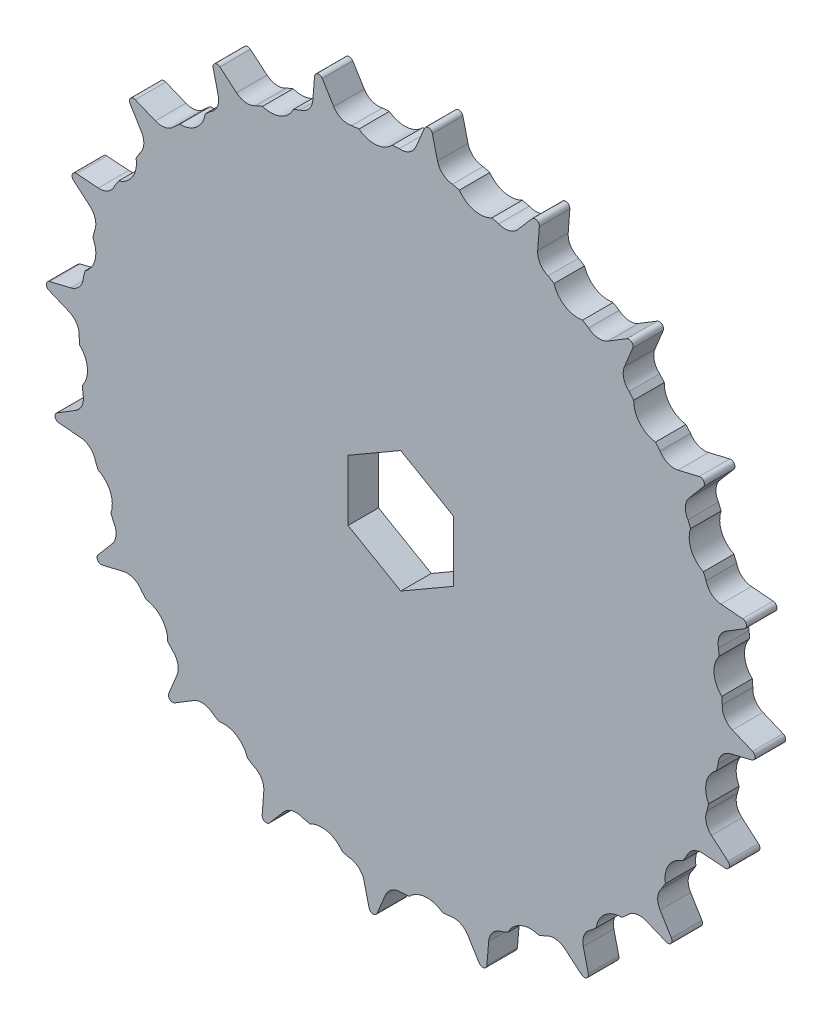
from build123d import *

# Parameters (mm, degrees)
BOSS_EXTRUDE1_DEPTH                 = 7.3
SKETCH2_R                           = 12.5
BOSS_EXTRUDE2_DEPTH                 = 40
FILLET1_R                           = 30
SKETCH3_R                           = 5
CUT_EXTRUDE1_DEPTH                  = 48.3
F_1_0MM_DOWEL_HOLE1_D               = 2.8
F_1_0MM_DOWEL_HOLE1_DEPTH           = 33.158795133
F_1_0MM_DOWEL_HOLE1_TIP             = 0.841204867
F_1_0MM_DOWEL_HOLE1_ON_FACE_2_D     = 2.8
F_1_0MM_DOWEL_HOLE1_ON_FACE_2_DEPTH = 33.158795133
F_1_0MM_DOWEL_HOLE1_ON_FACE_2_TIP   = 0.841204867
CUT_EXTRUDE2_DEPTH                  = 10
CIRPATTERN1_COUNT                   = 20
SKETCH6_W                           = 170.007054253
SKETCH6_H                           = 44.757292759
CUT_EXTRUDE3_DEPTH                  = 85.741056034
CUT_EXTRUDE3_DEPTH_BACK             = 85.741056034
CUT_EXTRUDE4_DEPTH                  = 1
CUT_EXTRUDE4_DEPTH_BACK             = 8.3


with BuildPart() as part:
    # Sketch1 → Boss-Extrude1 (new body)
    with BuildSketch(Plane.XY):
        with BuildLine():
            ThreePointArc((3.662609618, 79.321514688), (0, 76.88125), (-3.662609618, 79.321514688))
            Line((-3.662609618, 79.321514688), (-5.667701775, 84.126186191))
            ThreePointArc((-5.667701775, 84.126186191), (-6.669023137, 84.737973367), (-7.562311971, 83.977077135))
            Line((-7.562311971, 83.977077135), (-8.791101901, 78.917893592))
            ThreePointArc((-8.791101901, 78.917893592), (-12.026877215, 75.934714235), (-16.026135532, 77.77197684))
            Line((-16.026135532, 77.77197684), (-18.758157894, 82.203829344))
            ThreePointArc((-18.758157894, 82.203829344), (-19.842855928, 82.651443234), (-20.606116499, 81.760173735))
            Line((-20.606116499, 81.760173735), (-21.028347314, 76.571052042))
            ThreePointArc((-21.028347314, 76.571052042), (-23.757612799, 73.118413793), (-27.995044802, 74.307434811))
            Line((-27.995044802, 74.307434811), (-31.386725911, 78.2573414))
            ThreePointArc((-31.386725911, 78.2573414), (-32.528091751, 78.529760263), (-33.142530051, 77.530063512))
            Line((-33.142530051, 77.530063512), (-32.747805028, 72.338777067))
            ThreePointArc((-32.747805028, 72.338777067), (-34.903357108, 68.501695338), (-39.274623159, 69.013197125))
            Line((-39.274623159, 69.013197125), (-43.242448569, 72.38389799))
            ThreePointArc((-43.242448569, 72.38389799), (-44.412378001, 72.47441397), (-44.862864519, 71.390905818))
            Line((-44.862864519, 71.390905818), (-43.660903098, 66.325281321))
            ThreePointArc((-43.660903098, 66.325281321), (-45.189664928, 62.198237799), (-49.587129948, 62.019625484))
            Line((-49.587129948, 62.019625484), (-54.03339863, 64.728122783))
            ThreePointArc((-54.03339863, 64.728122783), (-55.203084108, 64.634507076), (-55.478526372, 63.49386709))
            Line((-55.478526372, 63.49386709), (-53.498924832, 58.678637028))
            ThreePointArc((-53.498924832, 58.678637028), (-54.363253221, 54.363253221), (-58.678637028, 53.498924832))
            Line((-58.678637028, 53.498924832), (-63.49386709, 55.478526372))
            ThreePointArc((-63.49386709, 55.478526372), (-64.634507076, 55.203084108), (-64.728122783, 54.03339863))
            Line((-64.728122783, 54.03339863), (-62.019625484, 49.587129948))
            ThreePointArc((-62.019625484, 49.587129948), (-62.198237799, 45.189664928), (-66.325281321, 43.660903098))
            Line((-66.325281321, 43.660903098), (-71.390905818, 44.862864519))
            ThreePointArc((-71.390905818, 44.862864519), (-72.47441397, 44.412378001), (-72.38389799, 43.242448569))
            Line((-72.38389799, 43.242448569), (-69.013197125, 39.274623159))
            ThreePointArc((-69.013197125, 39.274623159), (-68.501695338, 34.903357108), (-72.338777067, 32.747805028))
            Line((-72.338777067, 32.747805028), (-77.530063512, 33.142530051))
            ThreePointArc((-77.530063512, 33.142530051), (-78.529760263, 32.528091751), (-78.2573414, 31.386725911))
            Line((-78.2573414, 31.386725911), (-74.307434811, 27.995044802))
            ThreePointArc((-74.307434811, 27.995044802), (-73.118413793, 23.757612799), (-76.571052042, 21.028347314))
            Line((-76.571052042, 21.028347314), (-81.760173735, 20.606116499))
            ThreePointArc((-81.760173735, 20.606116499), (-82.651443234, 19.842855928), (-82.203829344, 18.758157894))
            Line((-82.203829344, 18.758157894), (-77.77197684, 16.026135532))
            ThreePointArc((-77.77197684, 16.026135532), (-75.934714235, 12.026877215), (-78.917893592, 8.791101901))
            Line((-78.917893592, 8.791101901), (-83.977077135, 7.562311971))
            ThreePointArc((-83.977077135, 7.562311971), (-84.737973367, 6.669023137), (-84.126186191, 5.667701775))
            Line((-84.126186191, 5.667701775), (-79.321514688, 3.662609618))
            ThreePointArc((-79.321514688, 3.662609618), (-76.88125, 0), (-79.321514688, -3.662609618))
            Line((-79.321514688, -3.662609618), (-84.126186191, -5.667701775))
            ThreePointArc((-84.126186191, -5.667701775), (-84.737973367, -6.669023137), (-83.977077135, -7.562311971))
            Line((-83.977077135, -7.562311971), (-78.917893592, -8.791101901))
            ThreePointArc((-78.917893592, -8.791101901), (-75.934714235, -12.026877215), (-77.77197684, -16.026135532))
            Line((-77.77197684, -16.026135532), (-82.203829344, -18.758157894))
            ThreePointArc((-82.203829344, -18.758157894), (-82.651443234, -19.842855928), (-81.760173735, -20.606116499))
            Line((-81.760173735, -20.606116499), (-76.571052042, -21.028347314))
            ThreePointArc((-76.571052042, -21.028347314), (-73.118413793, -23.757612799), (-74.307434811, -27.995044802))
            Line((-74.307434811, -27.995044802), (-78.2573414, -31.386725911))
            ThreePointArc((-78.2573414, -31.386725911), (-78.529760263, -32.528091751), (-77.530063512, -33.142530051))
            Line((-77.530063512, -33.142530051), (-72.338777067, -32.747805028))
            ThreePointArc((-72.338777067, -32.747805028), (-68.501695338, -34.903357108), (-69.013197125, -39.274623159))
            Line((-69.013197125, -39.274623159), (-72.38389799, -43.242448569))
            ThreePointArc((-72.38389799, -43.242448569), (-72.47441397, -44.412378001), (-71.390905818, -44.862864519))
            Line((-71.390905818, -44.862864519), (-66.325281321, -43.660903098))
            ThreePointArc((-66.325281321, -43.660903098), (-62.198237799, -45.189664928), (-62.019625484, -49.587129948))
            Line((-62.019625484, -49.587129948), (-64.728122783, -54.03339863))
            ThreePointArc((-64.728122783, -54.03339863), (-64.634507076, -55.203084108), (-63.49386709, -55.478526372))
            Line((-63.49386709, -55.478526372), (-58.678637028, -53.498924832))
            ThreePointArc((-58.678637028, -53.498924832), (-54.363253221, -54.363253221), (-53.498924832, -58.678637028))
            Line((-53.498924832, -58.678637028), (-55.478526372, -63.49386709))
            ThreePointArc((-55.478526372, -63.49386709), (-55.203084108, -64.634507076), (-54.03339863, -64.728122783))
            Line((-54.03339863, -64.728122783), (-49.587129948, -62.019625484))
            ThreePointArc((-49.587129948, -62.019625484), (-45.189664928, -62.198237799), (-43.660903098, -66.325281321))
            Line((-43.660903098, -66.325281321), (-44.862864519, -71.390905818))
            ThreePointArc((-44.862864519, -71.390905818), (-44.412378001, -72.47441397), (-43.242448569, -72.38389799))
            Line((-43.242448569, -72.38389799), (-39.274623159, -69.013197125))
            ThreePointArc((-39.274623159, -69.013197125), (-34.903357108, -68.501695338), (-32.747805028, -72.338777067))
            Line((-32.747805028, -72.338777067), (-33.142530051, -77.530063512))
            ThreePointArc((-33.142530051, -77.530063512), (-32.528091751, -78.529760263), (-31.386725911, -78.2573414))
            Line((-31.386725911, -78.2573414), (-27.995044802, -74.307434811))
            ThreePointArc((-27.995044802, -74.307434811), (-23.757612799, -73.118413793), (-21.028347314, -76.571052042))
            Line((-21.028347314, -76.571052042), (-20.606116499, -81.760173735))
            ThreePointArc((-20.606116499, -81.760173735), (-19.842855928, -82.651443234), (-18.758157894, -82.203829344))
            Line((-18.758157894, -82.203829344), (-16.026135532, -77.77197684))
            ThreePointArc((-16.026135532, -77.77197684), (-12.026877215, -75.934714235), (-8.791101901, -78.917893592))
            Line((-8.791101901, -78.917893592), (-7.562311971, -83.977077135))
            ThreePointArc((-7.562311971, -83.977077135), (-6.669023137, -84.737973367), (-5.667701775, -84.126186191))
            Line((-5.667701775, -84.126186191), (-3.662609618, -79.321514688))
            ThreePointArc((-3.662609618, -79.321514688), (0, -76.88125), (3.662609618, -79.321514688))
            Line((3.662609618, -79.321514688), (5.667701775, -84.126186191))
            ThreePointArc((5.667701775, -84.126186191), (6.669023137, -84.737973367), (7.562311971, -83.977077135))
            Line((7.562311971, -83.977077135), (8.791101901, -78.917893592))
            ThreePointArc((8.791101901, -78.917893592), (12.026877215, -75.934714235), (16.026135532, -77.77197684))
            Line((16.026135532, -77.77197684), (18.758157894, -82.203829344))
            ThreePointArc((18.758157894, -82.203829344), (19.842855928, -82.651443234), (20.606116499, -81.760173735))
            Line((20.606116499, -81.760173735), (21.028347314, -76.571052042))
            ThreePointArc((21.028347314, -76.571052042), (23.757612799, -73.118413793), (27.995044802, -74.307434811))
            Line((27.995044802, -74.307434811), (31.386725911, -78.2573414))
            ThreePointArc((31.386725911, -78.2573414), (32.528091751, -78.529760263), (33.142530051, -77.530063512))
            Line((33.142530051, -77.530063512), (32.747805028, -72.338777067))
            ThreePointArc((32.747805028, -72.338777067), (34.903357108, -68.501695338), (39.274623159, -69.013197125))
            Line((39.274623159, -69.013197125), (43.242448569, -72.38389799))
            ThreePointArc((43.242448569, -72.38389799), (44.412378001, -72.47441397), (44.862864519, -71.390905818))
            Line((44.862864519, -71.390905818), (43.660903098, -66.325281321))
            ThreePointArc((43.660903098, -66.325281321), (45.189664928, -62.198237799), (49.587129948, -62.019625484))
            Line((49.587129948, -62.019625484), (54.03339863, -64.728122783))
            ThreePointArc((54.03339863, -64.728122783), (55.203084108, -64.634507076), (55.478526372, -63.49386709))
            Line((55.478526372, -63.49386709), (53.498924832, -58.678637028))
            ThreePointArc((53.498924832, -58.678637028), (54.363253221, -54.363253221), (58.678637028, -53.498924832))
            Line((58.678637028, -53.498924832), (63.49386709, -55.478526372))
            ThreePointArc((63.49386709, -55.478526372), (64.634507076, -55.203084108), (64.728122783, -54.03339863))
            Line((64.728122783, -54.03339863), (62.019625484, -49.587129948))
            ThreePointArc((62.019625484, -49.587129948), (62.198237799, -45.189664928), (66.325281321, -43.660903098))
            Line((66.325281321, -43.660903098), (71.390905818, -44.862864519))
            ThreePointArc((71.390905818, -44.862864519), (72.47441397, -44.412378001), (72.38389799, -43.242448569))
            Line((72.38389799, -43.242448569), (69.013197125, -39.274623159))
            ThreePointArc((69.013197125, -39.274623159), (68.501695338, -34.903357108), (72.338777067, -32.747805028))
            Line((72.338777067, -32.747805028), (77.530063512, -33.142530051))
            ThreePointArc((77.530063512, -33.142530051), (78.529760263, -32.528091751), (78.2573414, -31.386725911))
            Line((78.2573414, -31.386725911), (74.307434811, -27.995044802))
            ThreePointArc((74.307434811, -27.995044802), (73.118413793, -23.757612799), (76.571052042, -21.028347314))
            Line((76.571052042, -21.028347314), (81.760173735, -20.606116499))
            ThreePointArc((81.760173735, -20.606116499), (82.651443234, -19.842855928), (82.203829344, -18.758157894))
            Line((82.203829344, -18.758157894), (77.77197684, -16.026135532))
            ThreePointArc((77.77197684, -16.026135532), (75.934714235, -12.026877215), (78.917893592, -8.791101901))
            Line((78.917893592, -8.791101901), (83.977077135, -7.562311971))
            ThreePointArc((83.977077135, -7.562311971), (84.737973367, -6.669023137), (84.126186191, -5.667701775))
            Line((84.126186191, -5.667701775), (79.321514688, -3.662609618))
            ThreePointArc((79.321514688, -3.662609618), (76.88125, 0), (79.321514688, 3.662609618))
            Line((79.321514688, 3.662609618), (84.126186191, 5.667701775))
            ThreePointArc((84.126186191, 5.667701775), (84.737973367, 6.669023137), (83.977077135, 7.562311971))
            Line((83.977077135, 7.562311971), (78.917893592, 8.791101901))
            ThreePointArc((78.917893592, 8.791101901), (75.934714235, 12.026877215), (77.77197684, 16.026135532))
            Line((77.77197684, 16.026135532), (82.203829344, 18.758157894))
            ThreePointArc((82.203829344, 18.758157894), (82.651443234, 19.842855928), (81.760173735, 20.606116499))
            Line((81.760173735, 20.606116499), (76.571052042, 21.028347314))
            ThreePointArc((76.571052042, 21.028347314), (73.118413793, 23.757612799), (74.307434811, 27.995044802))
            Line((74.307434811, 27.995044802), (78.2573414, 31.386725911))
            ThreePointArc((78.2573414, 31.386725911), (78.529760263, 32.528091751), (77.530063512, 33.142530051))
            Line((77.530063512, 33.142530051), (72.338777067, 32.747805028))
            ThreePointArc((72.338777067, 32.747805028), (68.501695338, 34.903357108), (69.013197125, 39.274623159))
            Line((69.013197125, 39.274623159), (72.38389799, 43.242448569))
            ThreePointArc((72.38389799, 43.242448569), (72.47441397, 44.412378001), (71.390905818, 44.862864519))
            Line((71.390905818, 44.862864519), (66.325281321, 43.660903098))
            ThreePointArc((66.325281321, 43.660903098), (62.198237799, 45.189664928), (62.019625484, 49.587129948))
            Line((62.019625484, 49.587129948), (64.728122783, 54.03339863))
            ThreePointArc((64.728122783, 54.03339863), (64.634507076, 55.203084108), (63.49386709, 55.478526372))
            Line((63.49386709, 55.478526372), (58.678637028, 53.498924832))
            ThreePointArc((58.678637028, 53.498924832), (54.363253221, 54.363253221), (53.498924832, 58.678637028))
            Line((53.498924832, 58.678637028), (55.478526372, 63.49386709))
            ThreePointArc((55.478526372, 63.49386709), (55.203084108, 64.634507076), (54.03339863, 64.728122783))
            Line((54.03339863, 64.728122783), (49.587129948, 62.019625484))
            ThreePointArc((49.587129948, 62.019625484), (45.189664928, 62.198237799), (43.660903098, 66.325281321))
            Line((43.660903098, 66.325281321), (44.862864519, 71.390905818))
            ThreePointArc((44.862864519, 71.390905818), (44.412378001, 72.47441397), (43.242448569, 72.38389799))
            Line((43.242448569, 72.38389799), (39.274623159, 69.013197125))
            ThreePointArc((39.274623159, 69.013197125), (34.903357108, 68.501695338), (32.747805028, 72.338777067))
            Line((32.747805028, 72.338777067), (33.142530051, 77.530063512))
            ThreePointArc((33.142530051, 77.530063512), (32.528091751, 78.529760263), (31.386725911, 78.2573414))
            Line((31.386725911, 78.2573414), (27.995044802, 74.307434811))
            ThreePointArc((27.995044802, 74.307434811), (23.757612799, 73.118413793), (21.028347314, 76.571052042))
            Line((21.028347314, 76.571052042), (20.606116499, 81.760173735))
            ThreePointArc((20.606116499, 81.760173735), (19.842855928, 82.651443234), (18.758157894, 82.203829344))
            Line((18.758157894, 82.203829344), (16.026135532, 77.77197684))
            ThreePointArc((16.026135532, 77.77197684), (12.026877215, 75.934714235), (8.791101901, 78.917893592))
            Line((8.791101901, 78.917893592), (7.562311971, 83.977077135))
            ThreePointArc((7.562311971, 83.977077135), (6.669023137, 84.737973367), (5.667701775, 84.126186191))
            Line((5.667701775, 84.126186191), (3.662609618, 79.321514688))
        make_face()
    extrude(amount=BOSS_EXTRUDE1_DEPTH)

    # Sketch2 → Boss-Extrude2 (add)
    with BuildSketch(Plane.XY.offset(7.3)):
        Circle(SKETCH2_R)
    extrude(amount=BOSS_EXTRUDE2_DEPTH)

    # Fillet1
    fillet1_edges = [part.edges().sort_by_distance(p)[0] for p in [
        (-12.5, 0, 7.3),
    ]]
    fillet(fillet1_edges, radius=FILLET1_R)

    # Sketch3 → Cut-Extrude1 (cut, through all)
    with BuildSketch(Plane.XY.offset(47.3)):
        Circle(SKETCH3_R)
    extrude(amount=-CUT_EXTRUDE1_DEPTH, mode=Mode.SUBTRACT)

    # Ø1.0mm Dowel Hole1
    with Locations(Plane(origin=(-6.81763654, -10.477109907, 42.020116055), x_dir=(-0.838168793, 0.545410923, 0), z_dir=(-0.545410923, -0.838168793, 0))):
        with Locations((0, 0)):
            Hole(F_1_0MM_DOWEL_HOLE1_D / 2, depth=F_1_0MM_DOWEL_HOLE1_DEPTH)
            with Locations((0, 0, -(F_1_0MM_DOWEL_HOLE1_DEPTH + F_1_0MM_DOWEL_HOLE1_TIP / 2))):  # 118° drill point
                Cone(0, F_1_0MM_DOWEL_HOLE1_D / 2, F_1_0MM_DOWEL_HOLE1_TIP, mode=Mode.SUBTRACT)

    # Ø1.0mm Dowel Hole1 on face 2
    with Locations(Plane(origin=(-11.068439798, 5.808583342, 41.658255729), x_dir=(-0.464687004, -0.885475007, 0), z_dir=(-0.885475007, 0.464687004, 0))):
        with Locations((0, 0)):
            Hole(F_1_0MM_DOWEL_HOLE1_ON_FACE_2_D / 2, depth=F_1_0MM_DOWEL_HOLE1_ON_FACE_2_DEPTH)
            with Locations((0, 0, -(F_1_0MM_DOWEL_HOLE1_ON_FACE_2_DEPTH + F_1_0MM_DOWEL_HOLE1_ON_FACE_2_TIP / 2))):  # 118° drill point
                Cone(0, F_1_0MM_DOWEL_HOLE1_ON_FACE_2_D / 2, F_1_0MM_DOWEL_HOLE1_ON_FACE_2_TIP, mode=Mode.SUBTRACT)

    # Sketch5 → Cut-Extrude2 (cut)
    with BuildSketch(Plane(origin=(0, 0, 0), x_dir=(-1, 0, 0), z_dir=(0, 0, -1))):
        with BuildLine():
            Line((-0.961651803, 76.999519203), (2.029100198, 76.764141915))
            ThreePointArc((2.029100198, 76.764141915), (5.896894701, 74.927151382), (10.004438868, 76.13646915))
            Line((10.004438868, 76.13646915), (12.995190869, 75.901091862))
            Line((12.995190869, 75.901091862), (13.647444473, 84.188759697))
            Line((13.647444473, 84.188759697), (-0.309398199, 85.287187037))
            Line((-0.309398199, 85.287187037), (-0.961651803, 76.999519203))
        make_face()
    cut_extrude2 = extrude(amount=-CUT_EXTRUDE2_DEPTH, mode=Mode.SUBTRACT)

    # CirPattern1: Cut-Extrude2 ×20 about axis
    cirpattern1_axis = Axis((0, 0, 0), (0, 0, 1))
    for i in range(1, CIRPATTERN1_COUNT):
        add(cut_extrude2.rotate(cirpattern1_axis, i * 360 / CIRPATTERN1_COUNT), mode=Mode.SUBTRACT)

    # Sketch6 → Cut-Extrude3 (cut, two sides)
    with BuildSketch(Plane(origin=(0, 0, 0), x_dir=(1, 0, 0), z_dir=(0, 1, 0))) as cut_extrude3_sk:
        with Locations((0.644460542, -29.67864638)):
            Rectangle(SKETCH6_W, SKETCH6_H)
    extrude(amount=CUT_EXTRUDE3_DEPTH, mode=Mode.SUBTRACT)
    extrude(cut_extrude3_sk.sketch, amount=-CUT_EXTRUDE3_DEPTH_BACK, mode=Mode.SUBTRACT)

    # Sketch7 → Cut-Extrude4 (cut, two sides)
    with BuildSketch(Plane(origin=(0, 0, 0), x_dir=(-1, 0, 0), z_dir=(0, 0, -1))) as cut_extrude4_sk:
        Polygon((12.6, -7.274613392), (12.6, 7.274613392), (0, 14.549226784), (-12.6, 7.274613392), (-12.6, -7.274613392), (0, -14.549226784), align=None)
    extrude(amount=CUT_EXTRUDE4_DEPTH, mode=Mode.SUBTRACT)
    extrude(cut_extrude4_sk.sketch, amount=-CUT_EXTRUDE4_DEPTH_BACK, mode=Mode.SUBTRACT)


solid = part.part
